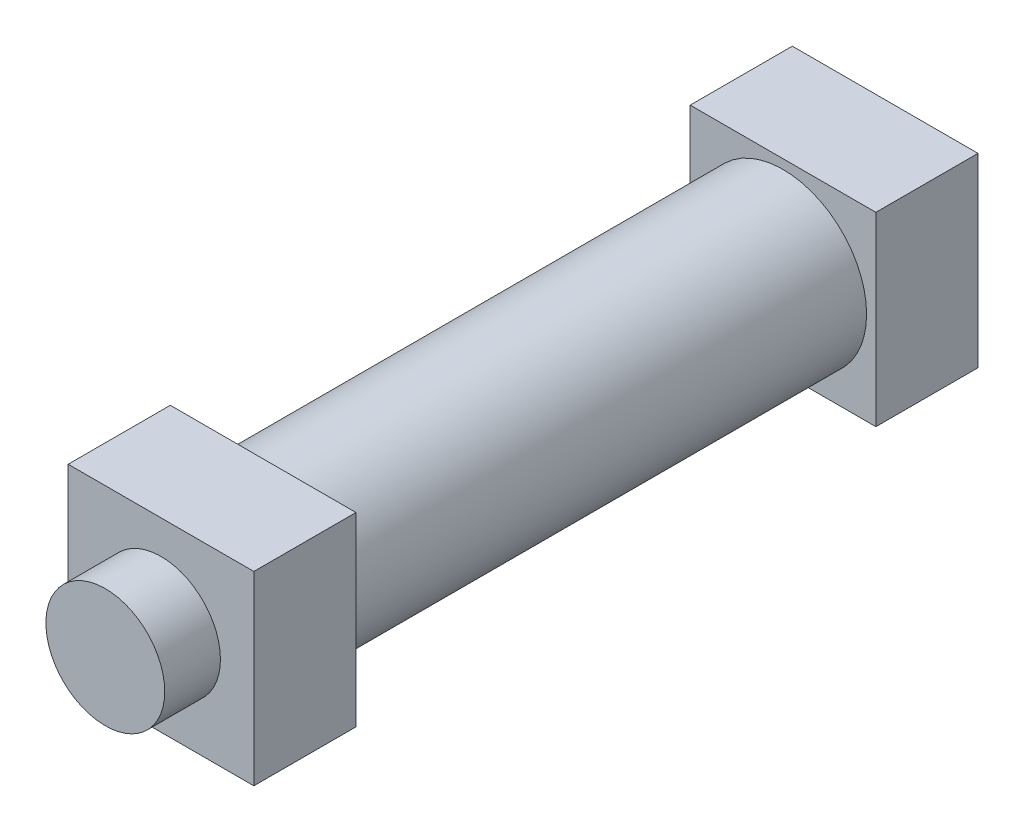
from build123d import *

# Parameters (mm, degrees)
SKETCH1_W           = 50
SKETCH1_H           = 50
BOSS_EXTRUDE1_DEPTH = 27.5
SKETCH3_R           = 22.5
BOSS_EXTRUDE2_DEPTH = 140
SKETCH4_W           = 50
SKETCH4_H           = 50
BOSS_EXTRUDE3_DEPTH = 27.5
SKETCH5_R           = 16
BOSS_EXTRUDE4_DEPTH = 15


with BuildPart() as part:
    # Sketch1 → Boss-Extrude1 (new body)
    with BuildSketch(Plane.XY):
        with Locations((25, 25)):
            Rectangle(SKETCH1_W, SKETCH1_H)
    extrude(amount=BOSS_EXTRUDE1_DEPTH)

    # Sketch3 → Boss-Extrude2 (add)
    with BuildSketch(Plane.XY.offset(27.5)):
        with Locations((25, 25)):
            Circle(SKETCH3_R)
    extrude(amount=BOSS_EXTRUDE2_DEPTH)

    # Sketch4 → Boss-Extrude3 (add)
    with BuildSketch(Plane.XY.offset(167.5)):
        with Locations((25, 25)):
            Rectangle(SKETCH4_W, SKETCH4_H)
    extrude(amount=BOSS_EXTRUDE3_DEPTH)

    # Sketch5 → Boss-Extrude4 (add)
    with BuildSketch(Plane.XY.offset(195)):
        with Locations((25, 25)):
            Circle(SKETCH5_R)
    extrude(amount=BOSS_EXTRUDE4_DEPTH)


solid = part.part
